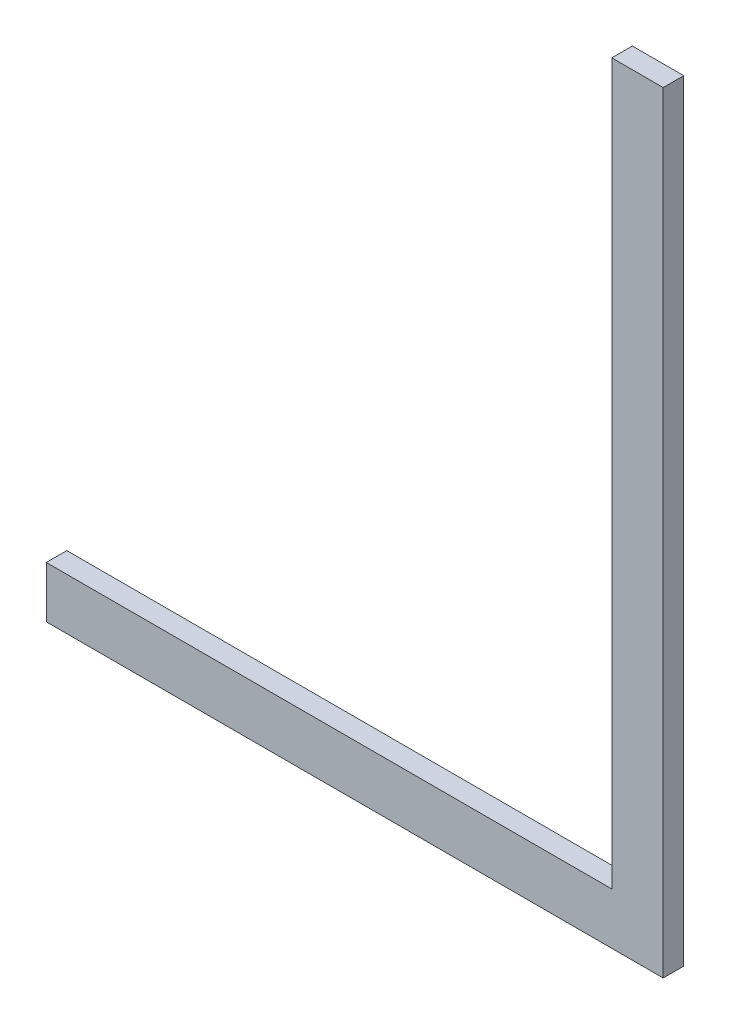
from build123d import *

# Parameters (mm, degrees)
SKETCH_1_W      = 10
SKETCH_1_H      = 150
EXTRUDE_1_DEPTH = 4
SKETCH_2_W      = 110
SKETCH_2_H      = 10
EXTRUDE_2_DEPTH = 4
SKETCH_3_R      = 3
EXTRUDE_3_DEPTH = 1


with BuildPart() as part:
    # 草图1 → 凸台-拉伸1 (new body)
    with BuildSketch(Plane.XY):
        with Locations((-0.878378378, 70.456081081)):
            Rectangle(SKETCH_1_W, SKETCH_1_H)
    extrude(amount=EXTRUDE_1_DEPTH)

    # 草图2 → 凸台-拉伸2 (add)
    with BuildSketch(Plane.XY.offset(4)):
        with Locations((-60.878378378, 0.456081081)):
            Rectangle(SKETCH_2_W, SKETCH_2_H)
    extrude(amount=-EXTRUDE_2_DEPTH)

    # 草图3 → 凸台-拉伸3 (add)
    with BuildSketch(Plane(origin=(0, 0, 0), x_dir=(-1, 0, 0), z_dir=(0, 0, -1))):
        with Locations((0.878378378, 135.456081081)):
            Circle(SKETCH_3_R)
    extrude(amount=EXTRUDE_3_DEPTH)


solid = part.part
